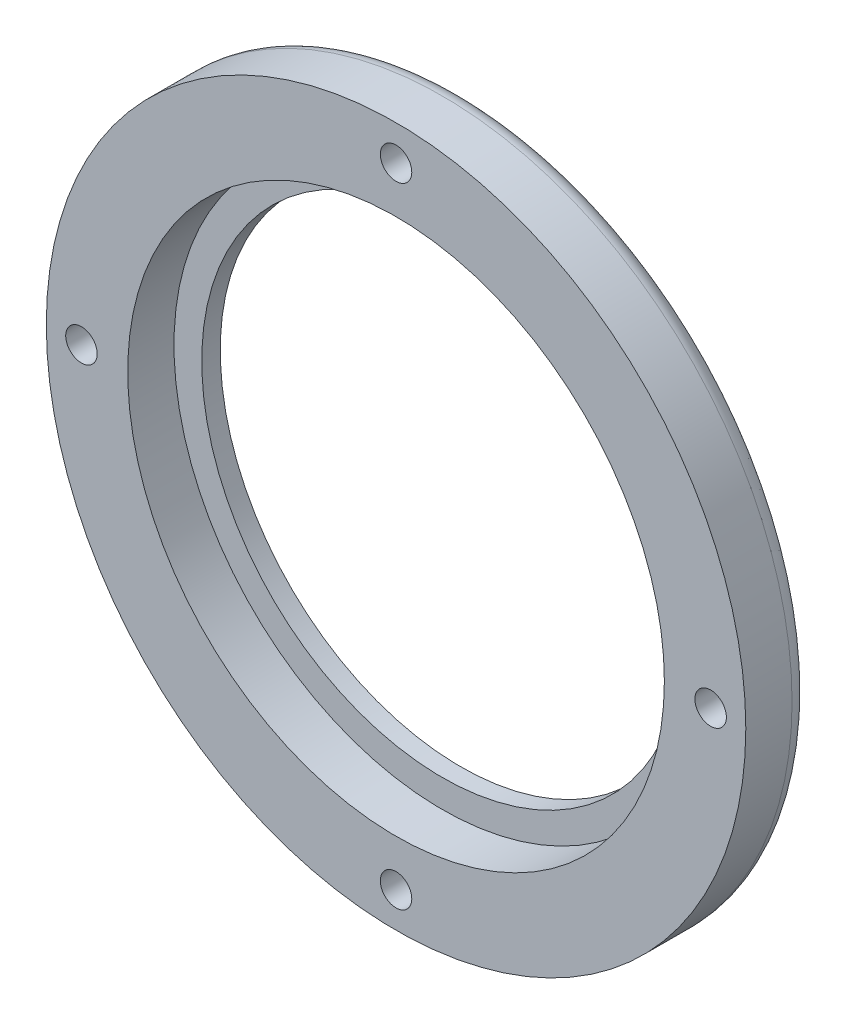
from build123d import *

# Parameters (mm, degrees)
SKETCH_1_R          = 37.8
SKETCH_1_R_2        = 26
EXTRUDE_1_DEPTH     = 7
SKETCH_2_R          = 29
CUT_EXTRUDE_1_DEPTH = 5
FILLET_1_R          = 2
SKETCH_3_R          = 1.7
CUT_EXTRUDE_2_DEPTH = 8
SKETCH_4_R          = 2.9
CUT_EXTRUDE_3_DEPTH = 2.5


with BuildPart() as part:
    # 草图1 → 凸台-拉伸1 (new body)
    with BuildSketch(Plane.XY):
        Circle(SKETCH_1_R)
        Circle(SKETCH_1_R_2, mode=Mode.SUBTRACT)
    extrude(amount=EXTRUDE_1_DEPTH)

    # 草图2 → 切除-拉伸1 (cut)
    with BuildSketch(Plane.XY.offset(7)):
        Circle(SKETCH_2_R)
    extrude(amount=-CUT_EXTRUDE_1_DEPTH, mode=Mode.SUBTRACT)

    # 圆角1
    fillet_1_edges = [part.edges().sort_by_distance(p)[0] for p in [
        (-37.8, 0, 0),
    ]]
    fillet(fillet_1_edges, radius=FILLET_1_R)

    # 草图3 → 切除-拉伸2 (cut)
    with BuildSketch(Plane.XY.offset(7)):
        with Locations((0, -34)):
            Circle(SKETCH_3_R)
        with Locations((-34, 0)):
            Circle(SKETCH_3_R)
        with Locations((0, 34)):
            Circle(SKETCH_3_R)
        with Locations((34, 0)):
            Circle(SKETCH_3_R)
    extrude(amount=-CUT_EXTRUDE_2_DEPTH, mode=Mode.SUBTRACT)

    # 草图4 → 切除-拉伸3 (cut)
    with BuildSketch(Plane(origin=(0, 0, 0), x_dir=(-1, 0, 0), z_dir=(0, 0, -1))):
        with Locations((-34, 0)):
            Circle(SKETCH_4_R)
        with Locations((0, 34)):
            Circle(SKETCH_4_R)
        with Locations((34, 0)):
            Circle(SKETCH_4_R)
        with Locations((0, -34)):
            Circle(SKETCH_4_R)
    extrude(amount=-CUT_EXTRUDE_3_DEPTH, mode=Mode.SUBTRACT)


solid = part.part
